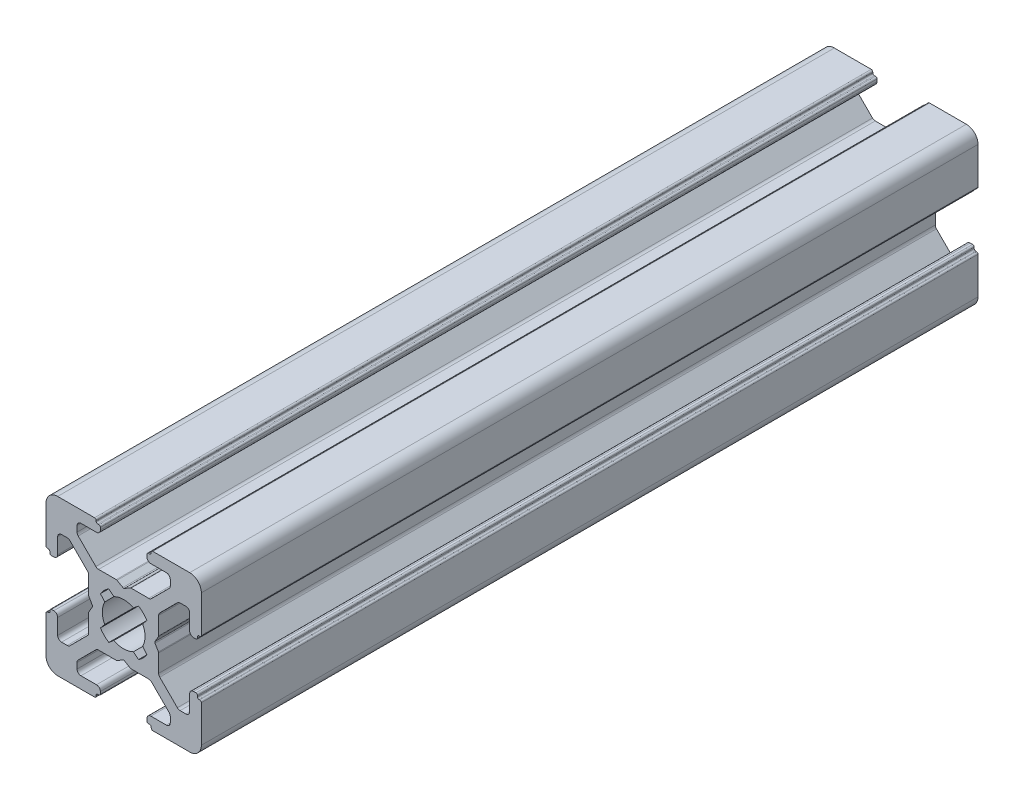
from build123d import *

# Parameters (mm, degrees)
EXTRUDE_1_DEPTH = 100


with BuildPart() as part:
    # Model → Бобышка-Вытянуть1 (new body)
    with BuildSketch(Plane.XY):
        with BuildLine():
            Line((197.369999772, 87.62), (192.62, 87.62))
            ThreePointArc((192.62, 87.62), (191.559339828, 87.180660172), (191.12, 86.12))
            Line((191.12, 86.12), (191.12, 81.369999605))
            ThreePointArc((191.12, 81.369999605), (191.178578644, 81.228578248), (191.32, 81.169999605))
            Line((191.32, 81.169999605), (191.420000268, 81.169999605))
            ThreePointArc((191.420000268, 81.169999605), (191.561421624, 81.111420961), (191.620000268, 80.969999605))
            Line((191.620000268, 80.969999605), (191.620000268, 80.82))
            ThreePointArc((191.620000268, 80.82), (191.678578912, 80.678578644), (191.820000268, 80.62))
            Line((191.820000268, 80.62), (192.120000268, 80.62))
            ThreePointArc((192.120000268, 80.62), (192.473553659, 80.766446609), (192.620000268, 81.12))
            Line((192.620000268, 81.12), (192.620000268, 83.119999605))
            ThreePointArc((192.620000268, 83.119999605), (192.766446877, 83.473552995), (193.120000268, 83.619999605))
            Line((193.120000268, 83.619999605), (193.852233315, 83.619999605))
            ThreePointArc((193.852233315, 83.619999605), (194.043575031, 83.581939371), (194.205786706, 83.473552995))
            Line((194.205786706, 83.473552995), (196.473553602, 81.205786099))
            ThreePointArc((196.473553602, 81.205786099), (196.581939977, 81.043574425), (196.620000211, 80.852232708))
            Line((196.620000211, 80.852232708), (196.620000211, 78.573589302))
            ThreePointArc((196.620000211, 78.573589302), (196.626815047, 78.52182549), (196.646795133, 78.473589297))
            Line((196.646795133, 78.473589297), (197.081880159, 77.719999969))
            ThreePointArc((197.081880159, 77.719999969), (197.108675071, 77.62), (197.081880159, 77.520000031))
            Line((197.081880159, 77.520000031), (196.646795133, 76.766410703))
            ThreePointArc((196.646795133, 76.766410703), (196.626815047, 76.71817451), (196.620000211, 76.666410698))
            Line((196.620000211, 76.666410698), (196.620000211, 74.387767292))
            ThreePointArc((196.620000211, 74.387767292), (196.581939977, 74.196425575), (196.473553602, 74.034213901))
            Line((196.473553602, 74.034213901), (194.205786706, 71.766447005))
            ThreePointArc((194.205786706, 71.766447005), (194.043575031, 71.658060629), (193.852233315, 71.620000395))
            Line((193.852233315, 71.620000395), (193.120000268, 71.620000395))
            ThreePointArc((193.120000268, 71.620000395), (192.766446877, 71.766447005), (192.620000268, 72.120000395))
            Line((192.620000268, 72.120000395), (192.620000268, 74.12))
            ThreePointArc((192.620000268, 74.12), (192.473553659, 74.473553391), (192.120000268, 74.62))
            Line((192.120000268, 74.62), (191.820000268, 74.62))
            ThreePointArc((191.820000268, 74.62), (191.678578912, 74.561421356), (191.620000268, 74.42))
            Line((191.620000268, 74.42), (191.620000268, 74.270000395))
            ThreePointArc((191.620000268, 74.270000395), (191.561421624, 74.128579039), (191.420000268, 74.070000395))
            Line((191.420000268, 74.070000395), (191.32, 74.070000395))
            ThreePointArc((191.32, 74.070000395), (191.178578644, 74.011421752), (191.12, 73.870000395))
            Line((191.12, 73.870000395), (191.12, 69.12))
            ThreePointArc((191.12, 69.12), (191.559339828, 68.059339828), (192.62, 67.62))
            Line((192.62, 67.62), (197.369999772, 67.62))
            ThreePointArc((197.369999772, 67.62), (197.511421129, 67.678578644), (197.569999772, 67.82))
            Line((197.569999772, 67.82), (197.569999772, 67.92))
            ThreePointArc((197.569999772, 67.92), (197.628578416, 68.061421356), (197.769999772, 68.12))
            Line((197.769999772, 68.12), (197.92, 68.12))
            ThreePointArc((197.92, 68.12), (198.061421356, 68.178578644), (198.12, 68.32))
            Line((198.12, 68.32), (198.12, 68.620000327))
            ThreePointArc((198.12, 68.620000327), (197.973553391, 68.973553717), (197.62, 69.120000327))
            Line((197.62, 69.120000327), (195.619999314, 69.120000327))
            ThreePointArc((195.619999314, 69.120000327), (195.266445923, 69.266446936), (195.119999314, 69.620000327))
            Line((195.119999314, 69.620000327), (195.119999314, 70.352233374))
            ThreePointArc((195.119999314, 70.352233374), (195.158059552, 70.543575101), (195.266445941, 70.705786781))
            Line((195.266445941, 70.705786781), (197.534212788, 72.973553408))
            ThreePointArc((197.534212788, 72.973553408), (197.696424456, 73.081939771), (197.887766161, 73.12))
            Line((197.887766161, 73.12), (200.166409688, 73.12))
            ThreePointArc((200.166409688, 73.12), (200.218173495, 73.126814834), (200.266409684, 73.146794917))
            Line((200.266409684, 73.146794917), (201.019999955, 73.581880438))
            ThreePointArc((201.019999955, 73.581880438), (201.12, 73.608675368), (201.220000045, 73.581880438))
            Line((201.220000045, 73.581880438), (201.973590316, 73.146794917))
            ThreePointArc((201.973590316, 73.146794917), (202.021826505, 73.126814834), (202.073590312, 73.12))
            Line((202.073590312, 73.12), (204.352233839, 73.12))
            ThreePointArc((204.352233839, 73.12), (204.543575544, 73.081939771), (204.705787212, 72.973553408))
            Line((204.705787212, 72.973553408), (206.973554059, 70.705786781))
            ThreePointArc((206.973554059, 70.705786781), (207.081940448, 70.543575101), (207.120000686, 70.352233374))
            Line((207.120000686, 70.352233374), (207.120000686, 69.620000327))
            ThreePointArc((207.120000686, 69.620000327), (206.973554077, 69.266446936), (206.620000686, 69.120000327))
            Line((206.620000686, 69.120000327), (204.62, 69.120000327))
            ThreePointArc((204.62, 69.120000327), (204.266446609, 68.973553717), (204.12, 68.620000327))
            Line((204.12, 68.620000327), (204.12, 68.32))
            ThreePointArc((204.12, 68.32), (204.178578644, 68.178578644), (204.32, 68.12))
            Line((204.32, 68.12), (204.470000228, 68.12))
            ThreePointArc((204.470000228, 68.12), (204.611421584, 68.061421356), (204.670000228, 67.92))
            Line((204.670000228, 67.92), (204.670000228, 67.82))
            ThreePointArc((204.670000228, 67.82), (204.728578871, 67.678578644), (204.870000228, 67.62))
            Line((204.870000228, 67.62), (209.62, 67.62))
            ThreePointArc((209.62, 67.62), (210.680660172, 68.059339828), (211.12, 69.12))
            Line((211.12, 69.12), (211.12, 73.870000395))
            ThreePointArc((211.12, 73.870000395), (211.061421356, 74.011421752), (210.92, 74.070000395))
            Line((210.92, 74.070000395), (210.819999732, 74.070000395))
            ThreePointArc((210.819999732, 74.070000395), (210.678578376, 74.128579039), (210.619999732, 74.270000395))
            Line((210.619999732, 74.270000395), (210.619999732, 74.42))
            ThreePointArc((210.619999732, 74.42), (210.561421088, 74.561421356), (210.419999732, 74.62))
            Line((210.419999732, 74.62), (210.119999732, 74.62))
            ThreePointArc((210.119999732, 74.62), (209.766446341, 74.473553391), (209.619999732, 74.12))
            Line((209.619999732, 74.12), (209.619999732, 72.120000395))
            ThreePointArc((209.619999732, 72.120000395), (209.473553123, 71.766447005), (209.119999732, 71.620000395))
            Line((209.119999732, 71.620000395), (208.387766685, 71.620000395))
            ThreePointArc((208.387766685, 71.620000395), (208.196424969, 71.658060629), (208.034213294, 71.766447005))
            Line((208.034213294, 71.766447005), (205.766446398, 74.034213901))
            ThreePointArc((205.766446398, 74.034213901), (205.658060023, 74.196425575), (205.619999789, 74.387767292))
            Line((205.619999789, 74.387767292), (205.619999789, 76.666410698))
            ThreePointArc((205.619999789, 76.666410698), (205.613184953, 76.71817451), (205.593204867, 76.766410703))
            Line((205.593204867, 76.766410703), (205.158119841, 77.520000031))
            ThreePointArc((205.158119841, 77.520000031), (205.131324929, 77.62), (205.158119841, 77.719999969))
            Line((205.158119841, 77.719999969), (205.593204867, 78.473589297))
            ThreePointArc((205.593204867, 78.473589297), (205.613184953, 78.52182549), (205.619999789, 78.573589302))
            Line((205.619999789, 78.573589302), (205.619999789, 80.852232708))
            ThreePointArc((205.619999789, 80.852232708), (205.658060023, 81.043574425), (205.766446398, 81.205786099))
            Line((205.766446398, 81.205786099), (208.034213294, 83.473552995))
            ThreePointArc((208.034213294, 83.473552995), (208.196424969, 83.581939371), (208.387766685, 83.619999605))
            Line((208.387766685, 83.619999605), (209.119999732, 83.619999605))
            ThreePointArc((209.119999732, 83.619999605), (209.473553123, 83.473552995), (209.619999732, 83.119999605))
            Line((209.619999732, 83.119999605), (209.619999732, 81.12))
            ThreePointArc((209.619999732, 81.12), (209.766446341, 80.766446609), (210.119999732, 80.62))
            Line((210.119999732, 80.62), (210.419999732, 80.62))
            ThreePointArc((210.419999732, 80.62), (210.561421088, 80.678578644), (210.619999732, 80.82))
            Line((210.619999732, 80.82), (210.619999732, 80.969999605))
            ThreePointArc((210.619999732, 80.969999605), (210.678578376, 81.111420961), (210.819999732, 81.169999605))
            Line((210.819999732, 81.169999605), (210.92, 81.169999605))
            ThreePointArc((210.92, 81.169999605), (211.061421356, 81.228578248), (211.12, 81.369999605))
            Line((211.12, 81.369999605), (211.12, 86.12))
            ThreePointArc((211.12, 86.12), (210.680660172, 87.180660172), (209.62, 87.62))
            Line((209.62, 87.62), (204.870000228, 87.62))
            ThreePointArc((204.870000228, 87.62), (204.728578871, 87.561421356), (204.670000228, 87.42))
            Line((204.670000228, 87.42), (204.670000228, 87.32))
            ThreePointArc((204.670000228, 87.32), (204.611421584, 87.178578644), (204.470000228, 87.12))
            Line((204.470000228, 87.12), (204.32, 87.12))
            ThreePointArc((204.32, 87.12), (204.178578644, 87.061421356), (204.12, 86.92))
            Line((204.12, 86.92), (204.12, 86.619999673))
            ThreePointArc((204.12, 86.619999673), (204.266446609, 86.266446283), (204.62, 86.119999673))
            Line((204.62, 86.119999673), (206.620000686, 86.119999673))
            ThreePointArc((206.620000686, 86.119999673), (206.973554077, 85.973553064), (207.120000686, 85.619999673))
            Line((207.120000686, 85.619999673), (207.120000686, 84.887766626))
            ThreePointArc((207.120000686, 84.887766626), (207.081940448, 84.696424899), (206.973554059, 84.534213219))
            Line((206.973554059, 84.534213219), (204.705787212, 82.266446592))
            ThreePointArc((204.705787212, 82.266446592), (204.543575544, 82.158060229), (204.352233839, 82.12))
            Line((204.352233839, 82.12), (202.073590312, 82.12))
            ThreePointArc((202.073590312, 82.12), (202.021826505, 82.113185166), (201.973590316, 82.093205083))
            Line((201.973590316, 82.093205083), (201.220000045, 81.658119562))
            ThreePointArc((201.220000045, 81.658119562), (201.12, 81.631324632), (201.019999955, 81.658119562))
            Line((201.019999955, 81.658119562), (200.266409684, 82.093205083))
            ThreePointArc((200.266409684, 82.093205083), (200.218173495, 82.113185166), (200.166409688, 82.12))
            Line((200.166409688, 82.12), (197.887766161, 82.12))
            ThreePointArc((197.887766161, 82.12), (197.696424456, 82.158060229), (197.534212788, 82.266446592))
            Line((197.534212788, 82.266446592), (195.266445941, 84.534213219))
            ThreePointArc((195.266445941, 84.534213219), (195.158059552, 84.696424899), (195.119999314, 84.887766626))
            Line((195.119999314, 84.887766626), (195.119999314, 85.619999673))
            ThreePointArc((195.119999314, 85.619999673), (195.266445923, 85.973553064), (195.619999314, 86.119999673))
            Line((195.619999314, 86.119999673), (197.62, 86.119999673))
            ThreePointArc((197.62, 86.119999673), (197.973553391, 86.266446283), (198.12, 86.619999673))
            Line((198.12, 86.619999673), (198.12, 86.92))
            ThreePointArc((198.12, 86.92), (198.061421356, 87.061421356), (197.92, 87.12))
            Line((197.92, 87.12), (197.769999772, 87.12))
            ThreePointArc((197.769999772, 87.12), (197.628578416, 87.178578644), (197.569999772, 87.32))
            Line((197.569999772, 87.32), (197.569999772, 87.42))
            ThreePointArc((197.569999772, 87.42), (197.511421129, 87.561421356), (197.369999772, 87.62))
        make_face()
        with BuildLine():
            Line((198.127825047, 79.529930962), (198.674704577, 78.878185317))
            ThreePointArc((198.674704577, 78.878185317), (198.37, 77.62), (198.674704577, 76.361814683))
            Line((198.674704577, 76.361814683), (198.127825047, 75.710069038))
            ThreePointArc((198.127825047, 75.710069038), (198.608262739, 75.111589515), (199.20610498, 74.630359038))
            Line((199.20610498, 74.630359038), (199.861814564, 75.174704638))
            ThreePointArc((199.861814564, 75.174704638), (201.12, 74.87), (202.378185436, 75.174704638))
            Line((202.378185436, 75.174704638), (203.03389502, 74.630359038))
            ThreePointArc((203.03389502, 74.630359038), (203.631737261, 75.111589515), (204.112174953, 75.710069038))
            Line((204.112174953, 75.710069038), (203.565295423, 76.361814683))
            ThreePointArc((203.565295423, 76.361814683), (203.87, 77.62), (203.565295423, 78.878185317))
            Line((203.565295423, 78.878185317), (204.112174953, 79.529930962))
            ThreePointArc((204.112174953, 79.529930962), (203.631737261, 80.128410485), (203.03389502, 80.609640962))
            Line((203.03389502, 80.609640962), (202.378185436, 80.065295362))
            ThreePointArc((202.378185436, 80.065295362), (201.12, 80.37), (199.861814564, 80.065295362))
            Line((199.861814564, 80.065295362), (199.20610498, 80.609640962))
            ThreePointArc((199.20610498, 80.609640962), (198.608262739, 80.128410485), (198.127825047, 79.529930962))
        make_face(mode=Mode.SUBTRACT)
    extrude(amount=EXTRUDE_1_DEPTH)


solid = part.part
